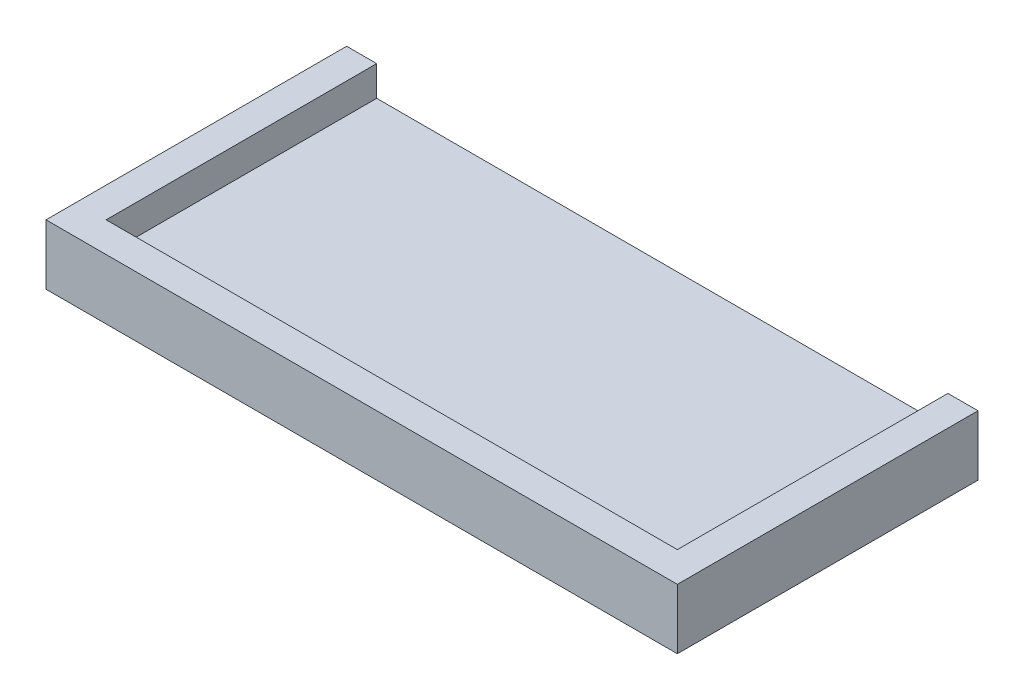
from build123d import *

# Parameters (mm, degrees)
SKETCH1_W           = 105
SKETCH1_H           = 50
BOSS_EXTRUDE1_DEPTH = 5
BOSS_EXTRUDE2_DEPTH = 5


with BuildPart() as part:
    # Sketch1 → Boss-Extrude1 (new body)
    with BuildSketch(Plane(origin=(0, 0, 0), x_dir=(1, 0, 0), z_dir=(0, 1, 0))):
        Rectangle(SKETCH1_W, SKETCH1_H)
    extrude(amount=BOSS_EXTRUDE1_DEPTH)

    # Sketch2 → Boss-Extrude2 (add)
    with BuildSketch(Plane(origin=(0, 5, 0), x_dir=(1, 0, 0), z_dir=(0, 1, 0))):
        Polygon((-52.5, 25), (-52.5, -25), (52.5, -25), (52.5, 25), (47.5, 25), (47.5, -20), (-47.5, -20), (-47.5, 25), align=None)
    extrude(amount=BOSS_EXTRUDE2_DEPTH)


solid = part.part
